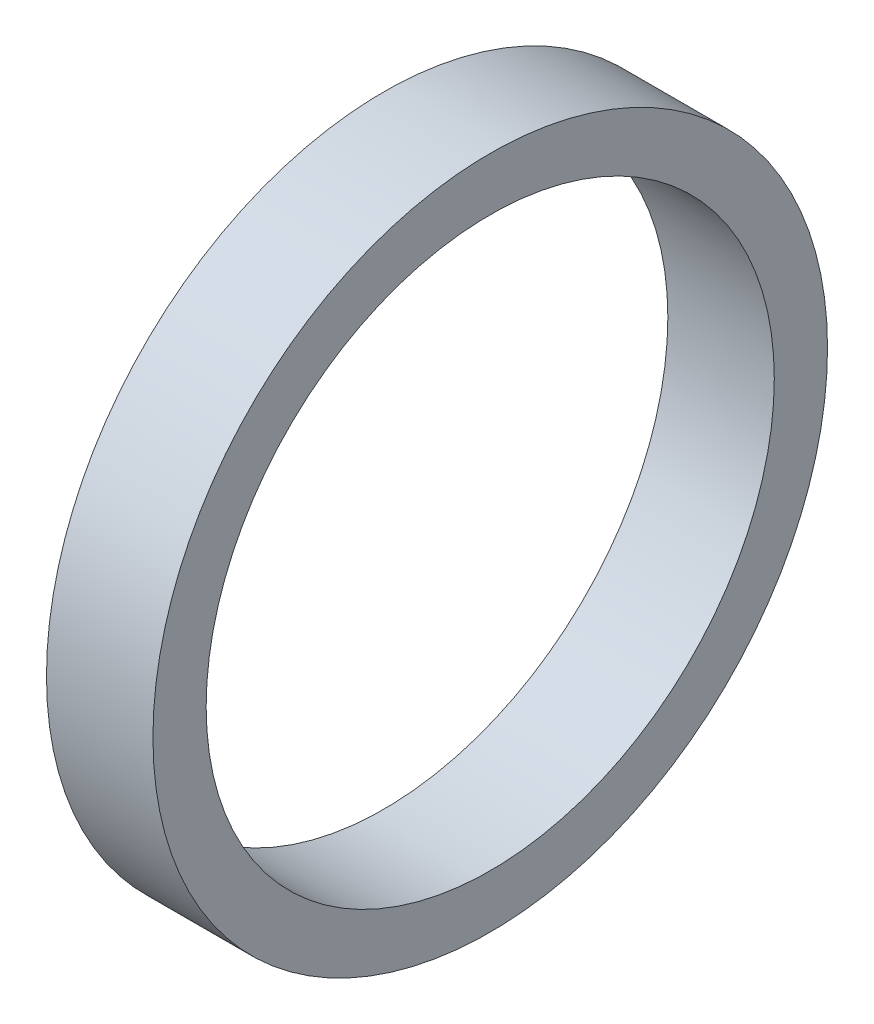
from build123d import *

# Parameters (mm, degrees)
CROQUIS1_W = 4
CROQUIS1_H = 2


with BuildPart() as part:
    # Croquis1 → Revolución1 (revolve)
    with BuildSketch(Plane(origin=(0, 0, 0), x_dir=(1, 0, 0), z_dir=(0, 1, 0))):
        with Locations((-2, 11.675)):
            Rectangle(CROQUIS1_W, CROQUIS1_H)
    revolve(axis=Axis((-20.785091056, 0, 0), (1, 0, 0)))


solid = part.part
